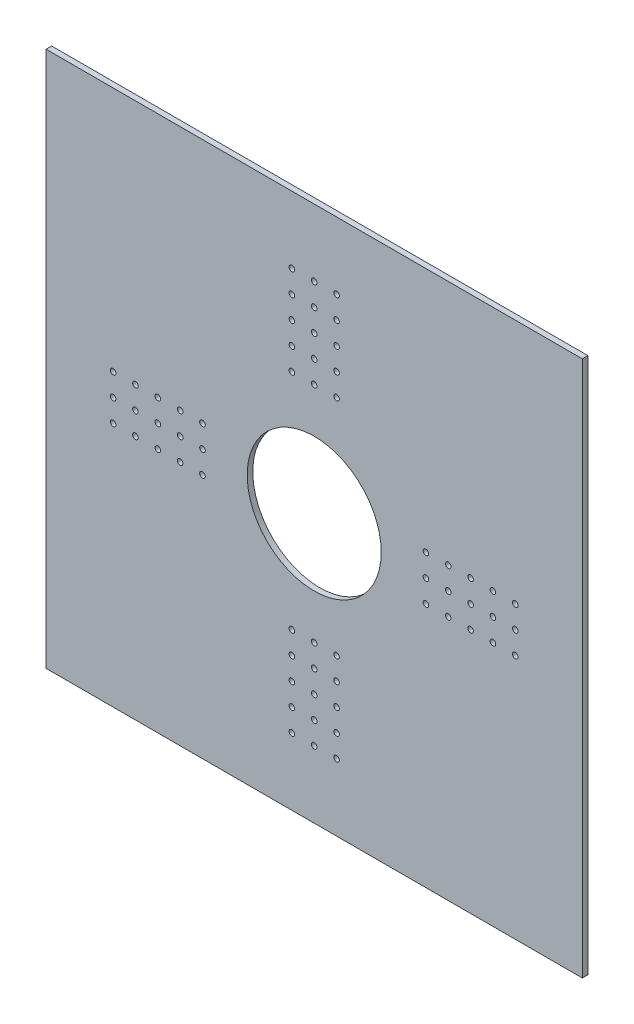
from build123d import *

# Parameters (mm, degrees)
SKETCH1_W                    = 609.6
SKETCH1_H                    = 609.6
SKETCH1_R                    = 76.2
BOSS_EXTRUDE1_DEPTH          = 6.35
SKETCH3_R                    = 3.175
CUT_EXTRUDE1_DEPTH           = 6.35
LPATTERN1_COUNT              = 5
LPATTERN1_PITCH              = 25.4
CIRPATTERN1_COUNT            = 4
CIRPATTERN1_COPY_1_SKETCH_R  = 3.175
CIRPATTERN1_COPY_1_DEPTH     = 6.35
CIRPATTERN1_COPY_2_SKETCH_R  = 3.175
CIRPATTERN1_COPY_2_DEPTH     = 6.35
CIRPATTERN1_COPY_3_SKETCH_R  = 3.175
CIRPATTERN1_COPY_3_DEPTH     = 6.35
CIRPATTERN1_COPY_4_SKETCH_R  = 3.175
CIRPATTERN1_COPY_4_DEPTH     = 6.35
CIRPATTERN1_COPY_5_SKETCH_R  = 3.175
CIRPATTERN1_COPY_5_DEPTH     = 6.35
CIRPATTERN1_COPY_6_SKETCH_R  = 3.175
CIRPATTERN1_COPY_6_DEPTH     = 6.35
CIRPATTERN1_COPY_7_SKETCH_R  = 3.175
CIRPATTERN1_COPY_7_DEPTH     = 6.35
CIRPATTERN1_COPY_8_SKETCH_R  = 3.175
CIRPATTERN1_COPY_8_DEPTH     = 6.35
CIRPATTERN1_COPY_9_SKETCH_R  = 3.175
CIRPATTERN1_COPY_9_DEPTH     = 6.35
CIRPATTERN1_COPY_10_SKETCH_R = 3.175
CIRPATTERN1_COPY_10_DEPTH    = 6.35
CIRPATTERN1_COPY_11_SKETCH_R = 3.175
CIRPATTERN1_COPY_11_DEPTH    = 6.35
CIRPATTERN1_COPY_12_SKETCH_R = 3.175
CIRPATTERN1_COPY_12_DEPTH    = 6.35


with BuildPart() as part:
    # Sketch1 → Boss-Extrude1 (new body)
    with BuildSketch(Plane.XY):
        Rectangle(SKETCH1_W, SKETCH1_H)
        Circle(SKETCH1_R, mode=Mode.SUBTRACT)
    extrude(amount=-BOSS_EXTRUDE1_DEPTH)

    # Sketch3 → Cut-Extrude1 (cut)
    with BuildSketch(Plane.XY):
        with Locations((-127, 0)):
            Circle(SKETCH3_R)
        with Locations((-127, 25.4)):
            Circle(SKETCH3_R)
        with Locations((-127, -25.4)):
            Circle(SKETCH3_R)
    cut_extrude1 = extrude(amount=-CUT_EXTRUDE1_DEPTH, mode=Mode.SUBTRACT)

    # LPattern1: Cut-Extrude1 ×5
    with Locations(*[(-i * LPATTERN1_PITCH, 0, 0) for i in range(1, LPATTERN1_COUNT)]):
        add(cut_extrude1, mode=Mode.SUBTRACT)

    # CirPattern1: Cut-Extrude1 ×4 about axis
    cirpattern1_axis = Axis((0, 0, 0), (0, 0, 1))
    for i in range(1, CIRPATTERN1_COUNT):
        add(cut_extrude1.rotate(cirpattern1_axis, i * 360 / CIRPATTERN1_COUNT), mode=Mode.SUBTRACT)

    # CirPattern1 copy 1 sketch → CirPattern1 copy 1 (cut)
    with BuildSketch(Plane(origin=(0, -25.4, 0), x_dir=(0, 1, 0), z_dir=(0, 0, 1))):
        with Locations((-127, 0)):
            Circle(CIRPATTERN1_COPY_1_SKETCH_R)
        with Locations((-127, 25.4)):
            Circle(CIRPATTERN1_COPY_1_SKETCH_R)
        with Locations((-127, -25.4)):
            Circle(CIRPATTERN1_COPY_1_SKETCH_R)
    extrude(amount=-CIRPATTERN1_COPY_1_DEPTH, mode=Mode.SUBTRACT)

    # CirPattern1 copy 2 sketch → CirPattern1 copy 2 (cut)
    with BuildSketch(Plane(origin=(25.4, 0, 0), x_dir=(-1, 0, 0), z_dir=(0, 0, 1))):
        with Locations((-127, 0)):
            Circle(CIRPATTERN1_COPY_2_SKETCH_R)
        with Locations((-127, 25.4)):
            Circle(CIRPATTERN1_COPY_2_SKETCH_R)
        with Locations((-127, -25.4)):
            Circle(CIRPATTERN1_COPY_2_SKETCH_R)
    extrude(amount=-CIRPATTERN1_COPY_2_DEPTH, mode=Mode.SUBTRACT)

    # CirPattern1 copy 3 sketch → CirPattern1 copy 3 (cut)
    with BuildSketch(Plane(origin=(0, 25.4, 0), x_dir=(0, -1, 0), z_dir=(0, 0, 1))):
        with Locations((-127, 0)):
            Circle(CIRPATTERN1_COPY_3_SKETCH_R)
        with Locations((-127, 25.4)):
            Circle(CIRPATTERN1_COPY_3_SKETCH_R)
        with Locations((-127, -25.4)):
            Circle(CIRPATTERN1_COPY_3_SKETCH_R)
    extrude(amount=-CIRPATTERN1_COPY_3_DEPTH, mode=Mode.SUBTRACT)

    # CirPattern1 copy 4 sketch → CirPattern1 copy 4 (cut)
    with BuildSketch(Plane(origin=(0, -50.8, 0), x_dir=(0, 1, 0), z_dir=(0, 0, 1))):
        with Locations((-127, 0)):
            Circle(CIRPATTERN1_COPY_4_SKETCH_R)
        with Locations((-127, 25.4)):
            Circle(CIRPATTERN1_COPY_4_SKETCH_R)
        with Locations((-127, -25.4)):
            Circle(CIRPATTERN1_COPY_4_SKETCH_R)
    extrude(amount=-CIRPATTERN1_COPY_4_DEPTH, mode=Mode.SUBTRACT)

    # CirPattern1 copy 5 sketch → CirPattern1 copy 5 (cut)
    with BuildSketch(Plane(origin=(50.8, 0, 0), x_dir=(-1, 0, 0), z_dir=(0, 0, 1))):
        with Locations((-127, 0)):
            Circle(CIRPATTERN1_COPY_5_SKETCH_R)
        with Locations((-127, 25.4)):
            Circle(CIRPATTERN1_COPY_5_SKETCH_R)
        with Locations((-127, -25.4)):
            Circle(CIRPATTERN1_COPY_5_SKETCH_R)
    extrude(amount=-CIRPATTERN1_COPY_5_DEPTH, mode=Mode.SUBTRACT)

    # CirPattern1 copy 6 sketch → CirPattern1 copy 6 (cut)
    with BuildSketch(Plane(origin=(0, 50.8, 0), x_dir=(0, -1, 0), z_dir=(0, 0, 1))):
        with Locations((-127, 0)):
            Circle(CIRPATTERN1_COPY_6_SKETCH_R)
        with Locations((-127, 25.4)):
            Circle(CIRPATTERN1_COPY_6_SKETCH_R)
        with Locations((-127, -25.4)):
            Circle(CIRPATTERN1_COPY_6_SKETCH_R)
    extrude(amount=-CIRPATTERN1_COPY_6_DEPTH, mode=Mode.SUBTRACT)

    # CirPattern1 copy 7 sketch → CirPattern1 copy 7 (cut)
    with BuildSketch(Plane(origin=(0, -76.2, 0), x_dir=(0, 1, 0), z_dir=(0, 0, 1))):
        with Locations((-127, 0)):
            Circle(CIRPATTERN1_COPY_7_SKETCH_R)
        with Locations((-127, 25.4)):
            Circle(CIRPATTERN1_COPY_7_SKETCH_R)
        with Locations((-127, -25.4)):
            Circle(CIRPATTERN1_COPY_7_SKETCH_R)
    extrude(amount=-CIRPATTERN1_COPY_7_DEPTH, mode=Mode.SUBTRACT)

    # CirPattern1 copy 8 sketch → CirPattern1 copy 8 (cut)
    with BuildSketch(Plane(origin=(76.2, 0, 0), x_dir=(-1, 0, 0), z_dir=(0, 0, 1))):
        with Locations((-127, 0)):
            Circle(CIRPATTERN1_COPY_8_SKETCH_R)
        with Locations((-127, 25.4)):
            Circle(CIRPATTERN1_COPY_8_SKETCH_R)
        with Locations((-127, -25.4)):
            Circle(CIRPATTERN1_COPY_8_SKETCH_R)
    extrude(amount=-CIRPATTERN1_COPY_8_DEPTH, mode=Mode.SUBTRACT)

    # CirPattern1 copy 9 sketch → CirPattern1 copy 9 (cut)
    with BuildSketch(Plane(origin=(0, 76.2, 0), x_dir=(0, -1, 0), z_dir=(0, 0, 1))):
        with Locations((-127, 0)):
            Circle(CIRPATTERN1_COPY_9_SKETCH_R)
        with Locations((-127, 25.4)):
            Circle(CIRPATTERN1_COPY_9_SKETCH_R)
        with Locations((-127, -25.4)):
            Circle(CIRPATTERN1_COPY_9_SKETCH_R)
    extrude(amount=-CIRPATTERN1_COPY_9_DEPTH, mode=Mode.SUBTRACT)

    # CirPattern1 copy 10 sketch → CirPattern1 copy 10 (cut)
    with BuildSketch(Plane(origin=(0, -101.6, 0), x_dir=(0, 1, 0), z_dir=(0, 0, 1))):
        with Locations((-127, 0)):
            Circle(CIRPATTERN1_COPY_10_SKETCH_R)
        with Locations((-127, 25.4)):
            Circle(CIRPATTERN1_COPY_10_SKETCH_R)
        with Locations((-127, -25.4)):
            Circle(CIRPATTERN1_COPY_10_SKETCH_R)
    extrude(amount=-CIRPATTERN1_COPY_10_DEPTH, mode=Mode.SUBTRACT)

    # CirPattern1 copy 11 sketch → CirPattern1 copy 11 (cut)
    with BuildSketch(Plane(origin=(101.6, 0, 0), x_dir=(-1, 0, 0), z_dir=(0, 0, 1))):
        with Locations((-127, 0)):
            Circle(CIRPATTERN1_COPY_11_SKETCH_R)
        with Locations((-127, 25.4)):
            Circle(CIRPATTERN1_COPY_11_SKETCH_R)
        with Locations((-127, -25.4)):
            Circle(CIRPATTERN1_COPY_11_SKETCH_R)
    extrude(amount=-CIRPATTERN1_COPY_11_DEPTH, mode=Mode.SUBTRACT)

    # CirPattern1 copy 12 sketch → CirPattern1 copy 12 (cut)
    with BuildSketch(Plane(origin=(0, 101.6, 0), x_dir=(0, -1, 0), z_dir=(0, 0, 1))):
        with Locations((-127, 0)):
            Circle(CIRPATTERN1_COPY_12_SKETCH_R)
        with Locations((-127, 25.4)):
            Circle(CIRPATTERN1_COPY_12_SKETCH_R)
        with Locations((-127, -25.4)):
            Circle(CIRPATTERN1_COPY_12_SKETCH_R)
    extrude(amount=-CIRPATTERN1_COPY_12_DEPTH, mode=Mode.SUBTRACT)


solid = part.part
